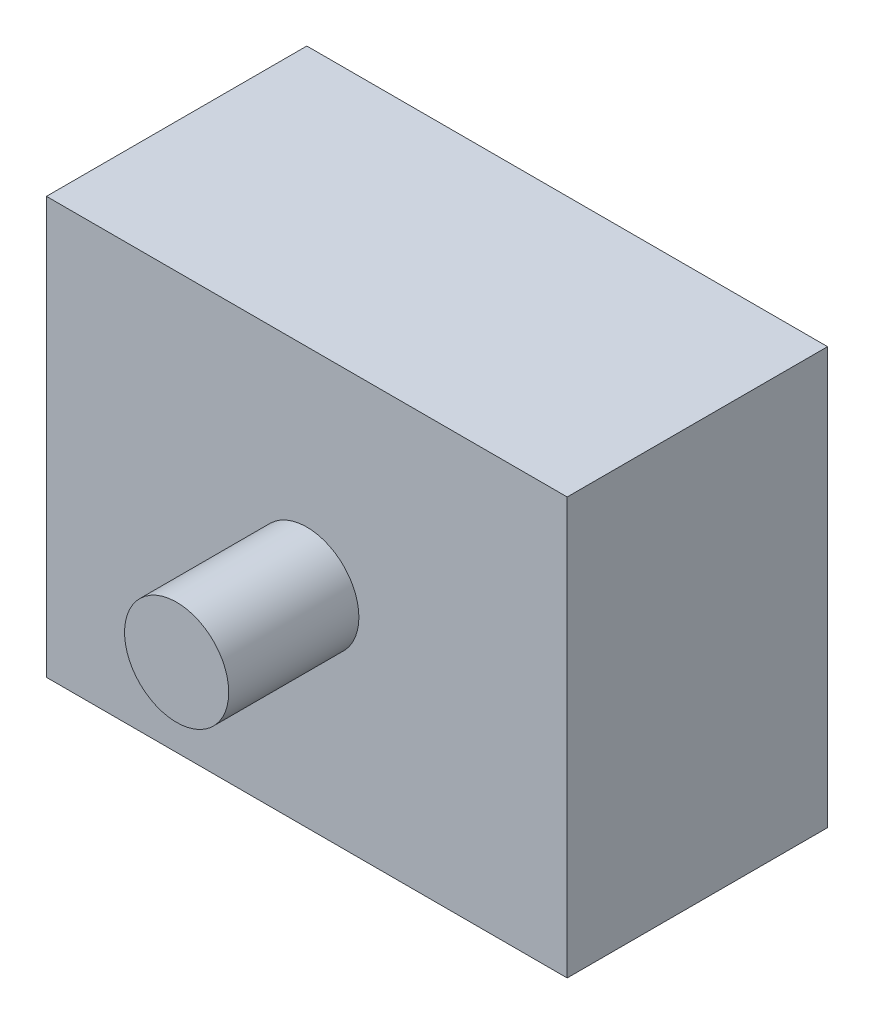
from build123d import *

# Parameters (mm, degrees)
SKETCH1_W           = 20
SKETCH1_H           = 16
SKETCH1_R           = 2
BOSS_EXTRUDE1_DEPTH = 10
SKETCH1_3_R         = 2
BOSS_EXTRUDE2_DEPTH = 15


with BuildPart() as part:
    # Sketch1 → Boss-Extrude1 (new body)
    with BuildSketch(Plane.XY):
        Rectangle(SKETCH1_W, SKETCH1_H)
        Circle(SKETCH1_R, mode=Mode.SUBTRACT)
    extrude(amount=BOSS_EXTRUDE1_DEPTH)

    # Sketch1_3 → Boss-Extrude2 (add)
    with BuildSketch(Plane.XY):
        Circle(SKETCH1_3_R)
    extrude(amount=BOSS_EXTRUDE2_DEPTH)


solid = part.part
